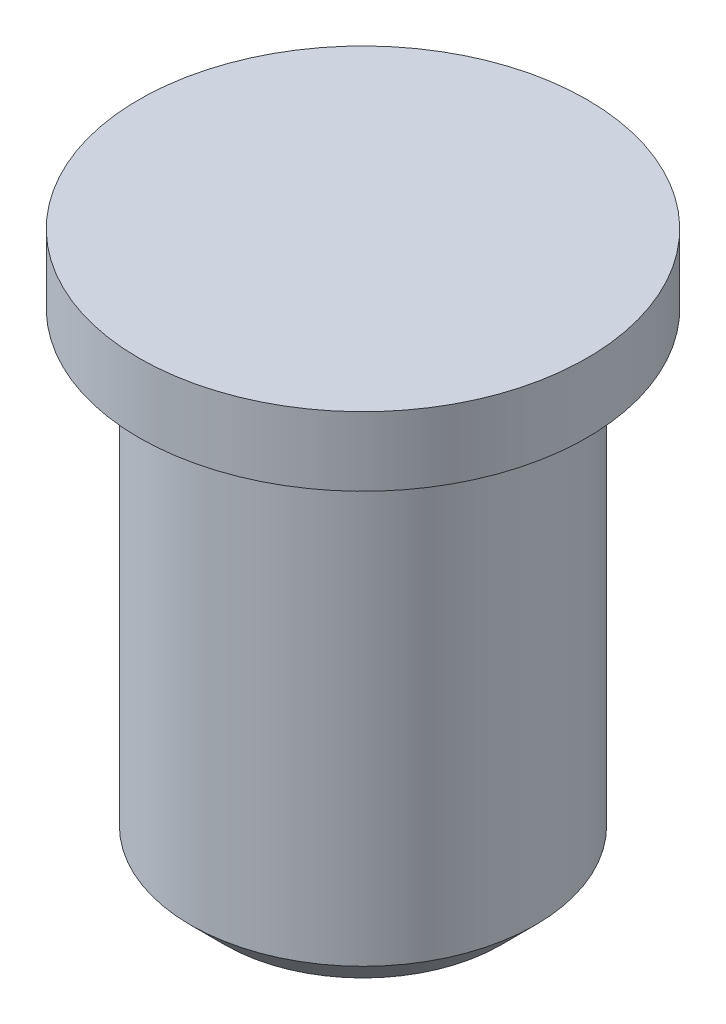
from build123d import *

# Parameters (mm, degrees)
CHAFL_N1_SIZE = 0.5


with BuildPart() as part:
    # Croquis1 → Revolución1 (revolve)
    with BuildSketch(Plane.XY):
        Polygon((0, 0), (3.25, 0), (3.25, -1), (2.5, -1), (2.5, -8), (0, -8), align=None)
    revolve(axis=Axis((0, 0, 0), (0, -1, 0)))

    # Chaflán1
    chafl_n1_edges = [part.edges().sort_by_distance(p)[0] for p in [
        (-2.5, -8, 0),
    ]]
    chamfer(chafl_n1_edges, length=CHAFL_N1_SIZE)


solid = part.part
